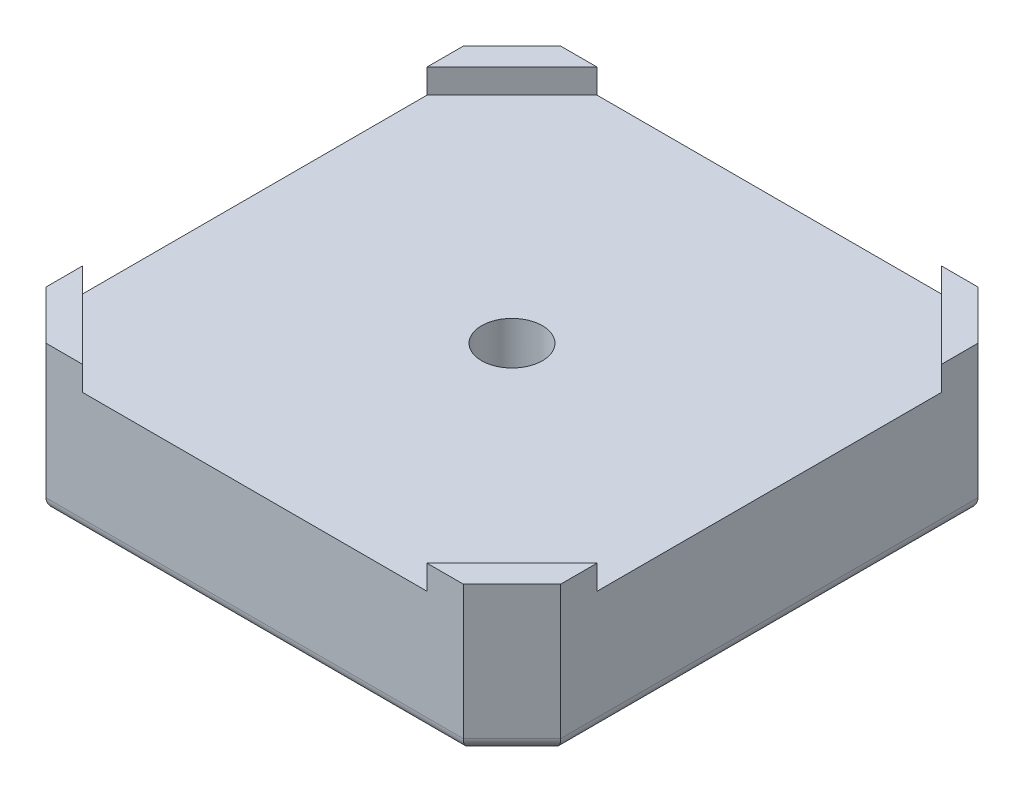
from build123d import *

# Parameters (mm, degrees)
BOSS_EXTRUDE3_DEPTH   = 12
CUT_EXTRUDE5_DEPTH    = 2
SKETCH12_R            = 2.5
CUT_EXTRUDE6_DEPTH    = 11
SKETCH13_R            = 5.5
CUT_EXTRUDE7_DEPTH    = 5
SKETCH16_R            = 11
SKETCH16_R_2          = 5.5
BOSS_EXTRUDE4_DEPTH   = 2
FILLET3_R             = 1
FILLET4_R             = 0.5
M3_TAPPED_HOLE1_D     = 2.5
M3_TAPPED_HOLE1_DEPTH = 7.5
M3_TAPPED_HOLE1_TIP   = 0.751075774
CHAMFER1_SIZE         = 0.3


with BuildPart() as part:
    # Sketch10 → Boss-Extrude3 (new body)
    with BuildSketch(Plane(origin=(0, 0, 0), x_dir=(1, 0, 0), z_dir=(0, 1, 0))):
        Polygon((-21.15, 17.15), (-17.15, 21.15), (17.15, 21.15), (21.15, 17.15), (21.15, -17.15), (17.15, -21.15), (-17.15, -21.15), (-21.15, -17.15), align=None)
    extrude(amount=BOSS_EXTRUDE3_DEPTH)

    # Sketch11 → Cut-Extrude5 (cut)
    with BuildSketch(Plane(origin=(0, 12, 0), x_dir=(1, 0, 0), z_dir=(0, 1, 0))):
        Polygon((-14.15, -21.15), (14.15, -21.15), (21.15, -14.15), (21.15, 14.15), (14.15, 21.15), (-14.15, 21.15), (-21.15, 14.15), (-21.15, -14.15), align=None)
    extrude(amount=-CUT_EXTRUDE5_DEPTH, mode=Mode.SUBTRACT)

    # Sketch12 → Cut-Extrude6 (cut, through all)
    with BuildSketch(Plane(origin=(0, 10, 0), x_dir=(1, 0, 0), z_dir=(0, 1, 0))):
        Circle(SKETCH12_R)
    extrude(amount=-CUT_EXTRUDE6_DEPTH, mode=Mode.SUBTRACT)

    # Sketch13 → Cut-Extrude7 (cut)
    with BuildSketch(Plane.XZ):
        Circle(SKETCH13_R)
    extrude(amount=-CUT_EXTRUDE7_DEPTH, mode=Mode.SUBTRACT)

    # Sketch16 → Boss-Extrude4 (add)
    with BuildSketch(Plane.XZ):
        Circle(SKETCH16_R)
        Circle(SKETCH16_R_2, mode=Mode.SUBTRACT)
    extrude(amount=BOSS_EXTRUDE4_DEPTH)

    # Fillet3
    fillet3_edges = [part.edges().sort_by_distance(p)[0] for p in [
        (-19.15, 0, -19.15),
        (0, 0, -21.15),
        (19.15, 0, -19.15),
        (21.15, 0, 0),
        (19.15, 0, 19.15),
        (0, 0, 21.15),
        (-19.15, 0, 19.15),
        (-21.15, 0, 0),
    ]]
    fillet(fillet3_edges, radius=FILLET3_R)

    # Fillet4
    fillet4_edges = [part.edges().sort_by_distance(p)[0] for p in [
        (-11, 0, 0),
        (-11, -2, 0),
        (-5.5, -2, 0),
    ]]
    fillet(fillet4_edges, radius=FILLET4_R)

    # M3 Tapped Hole1
    with Locations(Plane(origin=(0, 0, 0), x_dir=(-1, 0, 0), z_dir=(0, -1, 0))):
        with Locations((-15.5, -15.5), (15.5, -15.5), (15.5, 15.5), (-15.5, 15.5)):
            Hole(M3_TAPPED_HOLE1_D / 2, depth=M3_TAPPED_HOLE1_DEPTH)
            with Locations((0, 0, -(M3_TAPPED_HOLE1_DEPTH + M3_TAPPED_HOLE1_TIP / 2))):  # 118° drill point
                Cone(0, M3_TAPPED_HOLE1_D / 2, M3_TAPPED_HOLE1_TIP, mode=Mode.SUBTRACT)

    # Chamfer1
    chamfer1_edges = [part.edges().sort_by_distance(p)[0] for p in [
        (14.25, 0, -15.5),
        (-16.75, 0, -15.5),
        (-16.75, 0, 15.5),
        (14.25, 0, 15.5),
    ]]
    chamfer(chamfer1_edges, length=CHAMFER1_SIZE)


solid = part.part
